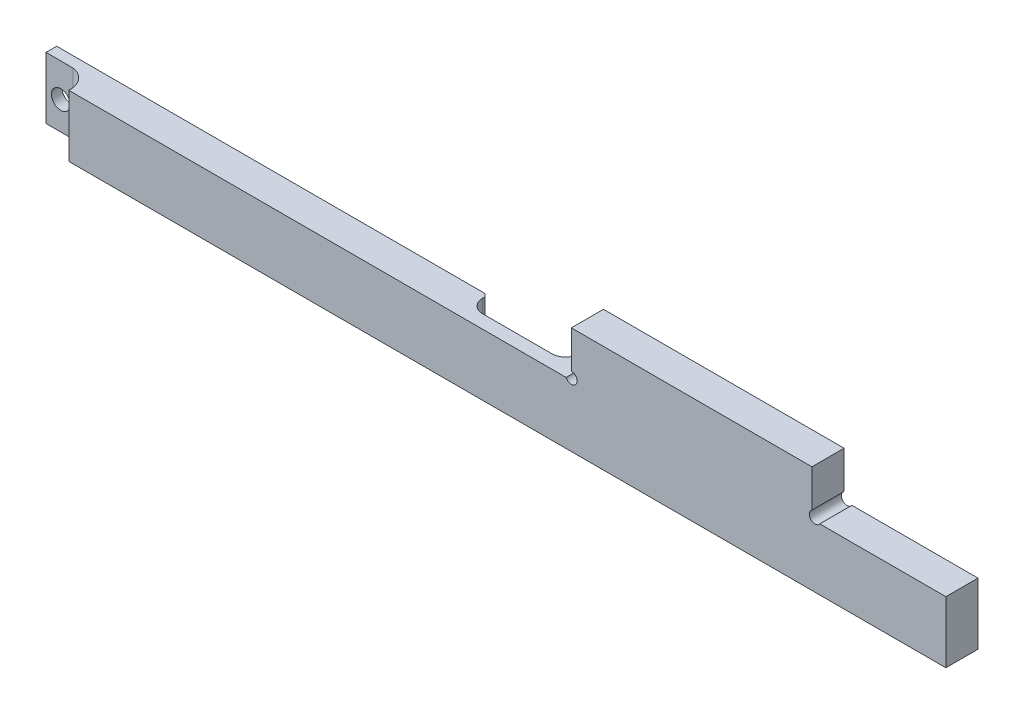
from build123d import *

# Parameters (mm, degrees)
SALIENTE_EXTRUIR1_DEPTH = 12
CROQUIS3_W              = 36
CROQUIS3_H              = 23
CORTAR_EXTRUIR2_DEPTH   = 7
REDONDEO1_R             = 5
CHAFL_N1_SIZE           = 1
CORTAR_EXTRUIR3_DEPTH   = 24
CROQUIS5_R              = 3.5
CORTAR_EXTRUIR4_DEPTH   = 20


with BuildPart() as part:
    # Croquis1 → Saliente-Extruir1 (new body)
    with BuildSketch(Plane.XY):
        with BuildLine():
            Line((216.337020033, 49.627252252), (216.337020033, 26.627252252))
            Line((216.337020033, 26.627252252), (-127.662979967, 26.627252252))
            Line((-127.662979967, 26.627252252), (-127.662979967, 49.627252252))
            Line((-127.662979967, 49.627252252), (74.548659913, 49.627252252))
            ThreePointArc((74.548659913, 49.627252252), (78.30523428, 49.32626093), (76.487020033, 52.627252252))
            Line((76.487020033, 52.627252252), (76.487020033, 66.627252252))
            Line((76.487020033, 66.627252252), (166.337020033, 66.627252252))
            Line((166.337020033, 66.627252252), (166.337020033, 52.627252252))
            ThreePointArc((166.337020033, 52.627252252), (165.940329064, 49.322890173), (169.254470914, 49.627252252))
            Line((169.254470914, 49.627252252), (216.337020033, 49.627252252))
        make_face()
    extrude(amount=SALIENTE_EXTRUIR1_DEPTH)

    # Croquis3 → Cortar-Extruir2 (cut)
    with BuildSketch(Plane(origin=(0, 0, 0), x_dir=(-1, 0, 0), z_dir=(0, 0, -1))):
        with Locations((-51.337020033, 38.127252252)):
            Rectangle(CROQUIS3_W, CROQUIS3_H)
    extrude(amount=-CORTAR_EXTRUIR2_DEPTH, mode=Mode.SUBTRACT)

    # Redondeo1
    redondeo1_edges = [part.edges().sort_by_distance(p)[0] for p in [
        (69.337020033, 38.127252252, 7),
        (33.337020033, 38.127252252, 7),
    ]]
    fillet(redondeo1_edges, radius=REDONDEO1_R)

    # Chaflán1
    chafl_n1_edges = [part.edges().sort_by_distance(p)[0] for p in [
        (33.337020033, 38.127252252, 0),
        (69.337020033, 38.127252252, 0),
    ]]
    chamfer(chafl_n1_edges, length=CHAFL_N1_SIZE)

    # Croquis4 → Cortar-Extruir3 (cut, through all)
    with BuildSketch(Plane(origin=(0, 49.627252252, 0), x_dir=(1, 0, 0), z_dir=(0, 1, 0))):
        with BuildLine():
            Line((-127.662979967, -12), (-127.662979967, -4))
            Line((-127.662979967, -4), (-117.662979967, -4))
            ThreePointArc((-117.662979967, -4), (-112.814866526, -6.70153283), (-111.162979967, -12))
            Line((-111.162979967, -12), (-127.662979967, -12))
        make_face()
    extrude(amount=-CORTAR_EXTRUIR3_DEPTH, mode=Mode.SUBTRACT)

    # Croquis5 → Cortar-Extruir4 (cut)
    with BuildSketch(Plane.XY.offset(14)):
        with Locations((-122.162979967, 37.127252252)):
            Circle(CROQUIS5_R)
    extrude(amount=-CORTAR_EXTRUIR4_DEPTH, mode=Mode.SUBTRACT)


solid = part.part
